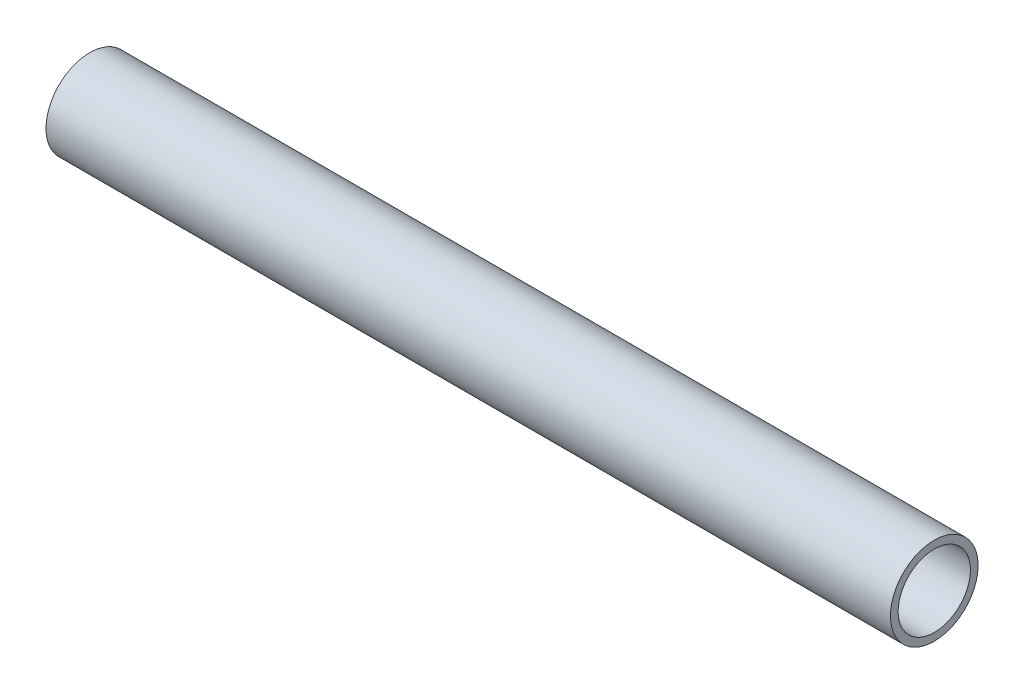
from build123d import *

# Parameters (mm, degrees)
SKETCH1_W = 406.4
SKETCH1_H = 3.683


with BuildPart() as part:
    # Sketch1 → Revolve1 (revolve)
    with BuildSketch(Plane.XY):
        with Locations((203.2, 19.2405)):
            Rectangle(SKETCH1_W, SKETCH1_H)
    revolve(axis=Axis((-17.138118992, 0, 0), (1, 0, 0)))


solid = part.part
